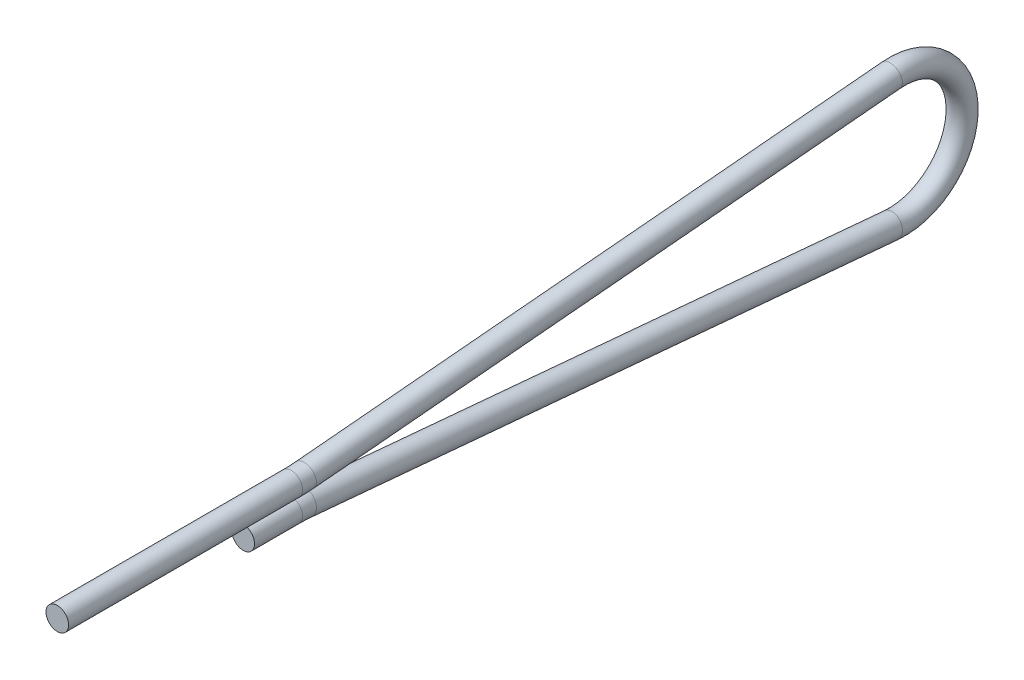
from build123d import *

# Parameters (mm, degrees)
SKETCH2_R = 0.7366


with BuildPart() as part:
    # Sweep1: sweep along a path in Sketch1
    with BuildLine(Plane(origin=(0, 0, 0), x_dir=(0, 0, -1), z_dir=(1, 0, 0))) as sweep1_path:
        Line((-42.483763873, -0.7366), (-39.364266321, -0.7366))
        ThreePointArc((-39.364266321, -0.7366), (-38.913706182, -0.746755379), (-38.464061165, -0.777200888))
        Line((-38.464061165, -0.777200888), (-0.381380916, -4.219399028))
        ThreePointArc((-0.381380916, -4.219399028), (4.2366, 0), (-0.381380916, 4.219399028))
        Line((-0.381380916, 4.219399028), (-38.464061165, 0.777200888))
        ThreePointArc((-38.464061165, 0.777200888), (-38.913706182, 0.746755379), (-39.364266321, 0.7366))
        Line((-39.364266321, 0.7366), (-42.483763873, 0.7366))
        Line((-42.483763873, 0.7366), (-54.56460022, 0.7366))
    # Sketch2 → Sweep1 (sweep)
    with BuildSketch(Plane.XY.offset(54.56460022)):
        with Locations((0, 0.7366)):
            Circle(SKETCH2_R)
    sweep(path=sweep1_path.line)


solid = part.part
